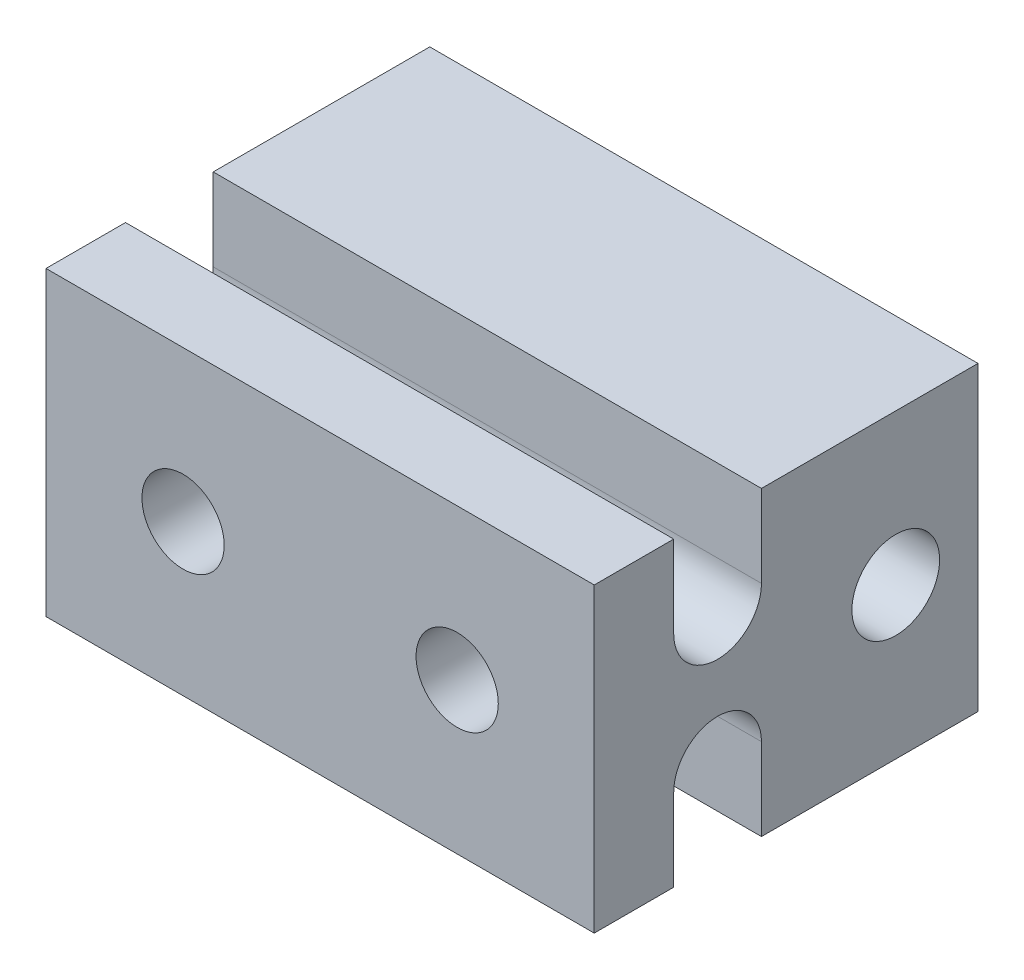
from build123d import *

# Parameters (mm, degrees)
SKETCH_2_W          = 20
SKETCH_2_H          = 11
EXTRUDE_1_DEPTH     = 14
SKETCH_4_R          = 1.6
CUT_EXTRUDE_1_DEPTH = 21
SKETCH_5_R          = 1.5
CUT_EXTRUDE_2_DEPTH = 2.9


with BuildPart() as part:
    # 草图2 → 凸台-拉伸1 (new body)
    with BuildSketch(Plane.XY):
        Rectangle(SKETCH_2_W, SKETCH_2_H)
    extrude(amount=-EXTRUDE_1_DEPTH)

    # 草图4 → 切除-拉伸1 (cut, through all)
    with BuildSketch(Plane(origin=(10, 0, 0), x_dir=(0, 0, -1), z_dir=(1, 0, 0))):
        with BuildLine():
            ThreePointArc((6.1, -2.5), (4.5, -0.9), (2.9, -2.5))
            Line((2.9, -2.5), (2.9, -5.5))
            Line((2.9, -5.5), (6.1, -5.5))
            Line((6.1, -5.5), (6.1, -2.5))
        make_face()
        with BuildLine():
            Line((2.9, 5.5), (2.9, 2.5))
            ThreePointArc((2.9, 2.5), (4.5, 0.9), (6.1, 2.5))
            Line((6.1, 2.5), (6.1, 5.5))
            Line((6.1, 5.5), (2.9, 5.5))
        make_face()
        with Locations((11, 0)):
            Circle(SKETCH_4_R)
    extrude(amount=-CUT_EXTRUDE_1_DEPTH, mode=Mode.SUBTRACT)

    # 草图5 → 切除-拉伸2 (cut)
    with BuildSketch(Plane.XY):
        with Locations((-5, 0)):
            Circle(SKETCH_5_R)
        with Locations((5, 0)):
            Circle(SKETCH_5_R)
    extrude(amount=-CUT_EXTRUDE_2_DEPTH, mode=Mode.SUBTRACT)


solid = part.part
